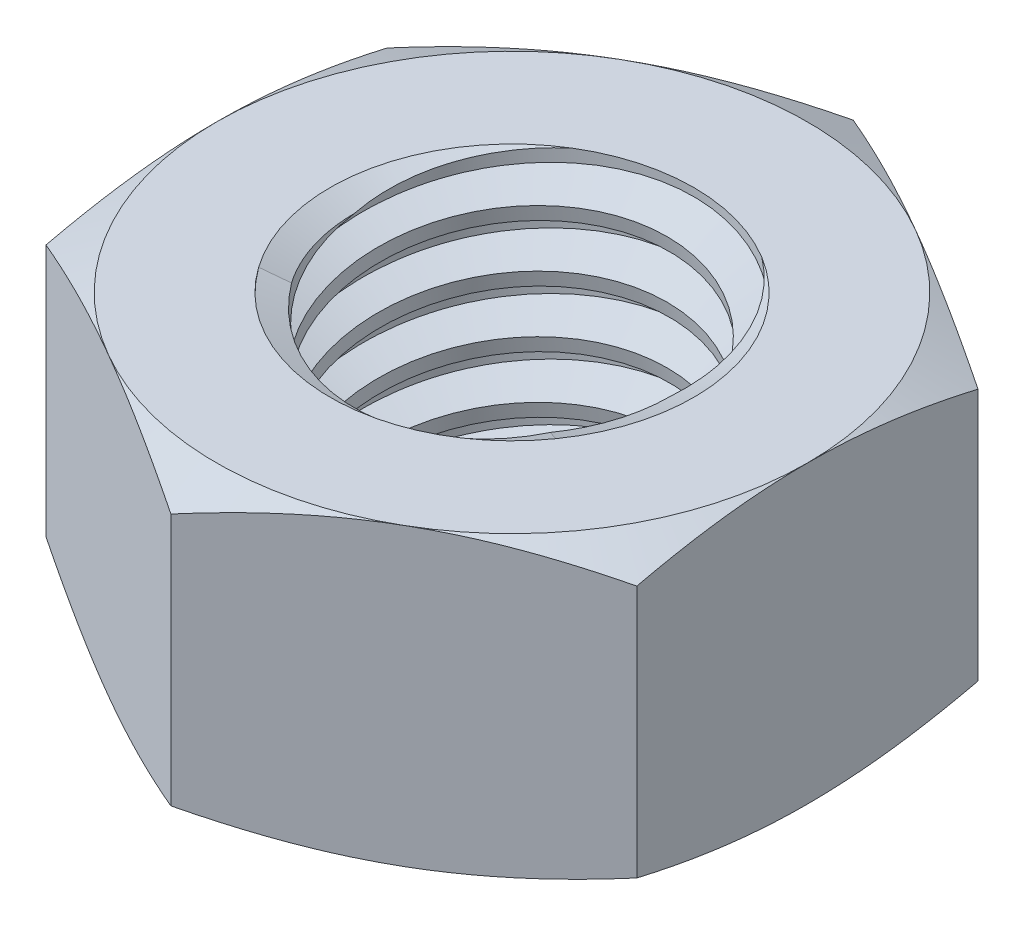
from build123d import *

# Parameters (mm, degrees)
EXTRUDE1_DEPTH      = 3.25
SKETCH2_W           = 4
SKETCH2_H           = 6.5
LPATTERN1_COUNT     = 5
LPATTERN1_PITCH     = 1.25
LPATTERN1_COL_COUNT = 2
LPATTERN1_COL_PITCH = 1.25


with BuildPart() as part:
    # Sketch1 → Extrude1 (new body, symmetric)
    with BuildSketch(Plane(origin=(0, 0, 0), x_dir=(1, 0, 0), z_dir=(0, 1, 0))):
        Polygon((0, 7.505553499), (-6.5, 3.75277675), (-6.5, -3.75277675), (0, -7.505553499), (6.5, -3.75277675), (6.5, 3.75277675), align=None)
    extrude(amount=EXTRUDE1_DEPTH, both=True)

    # Sketch4 → Cut-Revolve2 (revolve, cut)
    with BuildSketch(Plane(origin=(0, 0, 0), x_dir=(0, 0, -1), z_dir=(1, 0, 0))):
        Polygon((0, 3.25), (4, 3.25), (3.415953356, 2.977654577), (3.415953356, -2.977654577), (4, -3.25), (0, -3.25), align=None)
    revolve(axis=Axis((0, 3.25, 0), (0, 1, 0)), mode=Mode.SUBTRACT)


with BuildPart() as body_2:
    # Sketch2 → Revolve1 (revolve)
    with BuildSketch(Plane(origin=(0, 0, 0), x_dir=(0, 0, -1), z_dir=(1, 0, 0))):
        with Locations((2, 0)):
            Rectangle(SKETCH2_W, SKETCH2_H)
    revolve(axis=Axis((0, -7.25, 0), (0, 1, 0)))

    # Sketch3 → Cut-Revolve1 (revolve, cut)
    with BuildSketch(Plane(origin=(0, 0, 0), x_dir=(0, 0, -1), z_dir=(1, 0, 0))):
        Polygon((4.024121388, 3.09562312), (4.1929711, 2.014984958), (3.464196131, 2.296478487), (3.415953356, 2.605232247), align=None)
    cut_revolve1 = revolve(axis=Axis((0, 3.25, 0.208852549), (0, -0.988012034, -0.15437688)), mode=Mode.SUBTRACT)

    # LPattern1: Cut-Revolve1 ×5
    with Locations(*[(0, -i * LPATTERN1_PITCH, 0) for i in range(1, LPATTERN1_COUNT)]):
        add(cut_revolve1, mode=Mode.SUBTRACT)

    # LPattern1 col: Cut-Revolve1 ×2
    with Locations(*[(0, i * LPATTERN1_COL_PITCH, 0) for i in range(1, LPATTERN1_COL_COUNT)]):
        add(cut_revolve1, mode=Mode.SUBTRACT)


with BuildPart() as part_1:
    add(part.part)

    # Combine1: cut body 2
    add(body_2.part, mode=Mode.SUBTRACT)

    # Sketch5 → Cut-Revolve3 (revolve, cut)
    with BuildSketch(Plane(origin=(0, 0, 0), x_dir=(0, 0, -1), z_dir=(1, 0, 0))):
        Polygon((0, -3.25), (6.5, -3.25), (7.505553499, -2.781102703), (7.505553499, 2.781102703), (6.5, 3.25), (0, 3.25), (0, 4.52), (8.775553499, 4.52), (8.775553499, -4.52), (0, -4.52), align=None)
    revolve(axis=Axis((0, -3.25, 0), (0, 1, 0)), mode=Mode.SUBTRACT)


solid = part_1.part
